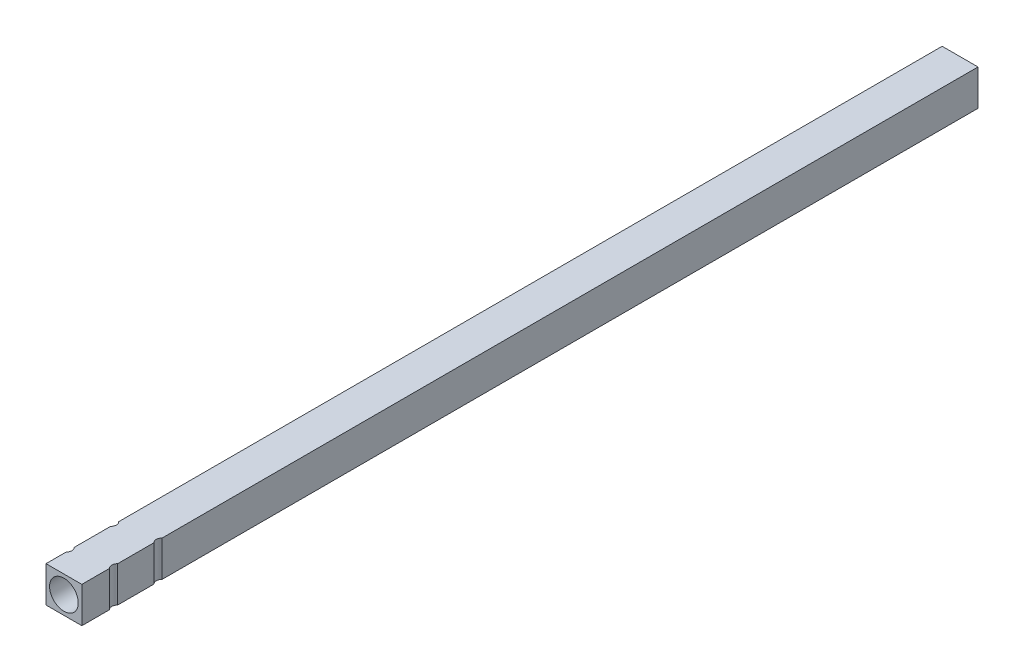
from build123d import *

# Parameters (mm, degrees)
SKETCH1_W           = 10
SKETCH1_H           = 10
SKETCH1_R           = 4
BOSS_EXTRUDE1_DEPTH = 250
SKETCH2_R           = 1.6
CUT_EXTRUDE1_DEPTH  = 11


with BuildPart() as part:
    # Sketch1 → Boss-Extrude1 (new body)
    with BuildSketch(Plane.XY):
        Rectangle(SKETCH1_W, SKETCH1_H)
        Circle(SKETCH1_R, mode=Mode.SUBTRACT)
    extrude(amount=BOSS_EXTRUDE1_DEPTH)

    # Sketch2 → Cut-Extrude1 (cut, through all)
    with BuildSketch(Plane.XZ.offset(5)):
        with Locations((-6.119289585, 243.266656382)):
            Circle(SKETCH2_R)
        with Locations((6.119289585, 228.733343618)):
            Circle(SKETCH2_R)
        with Locations((-6.119289585, 230.846914034)):
            Circle(SKETCH2_R)
        with Locations((6.119289585, 241.153085966)):
            Circle(SKETCH2_R)
    extrude(amount=-CUT_EXTRUDE1_DEPTH, mode=Mode.SUBTRACT)


solid = part.part
